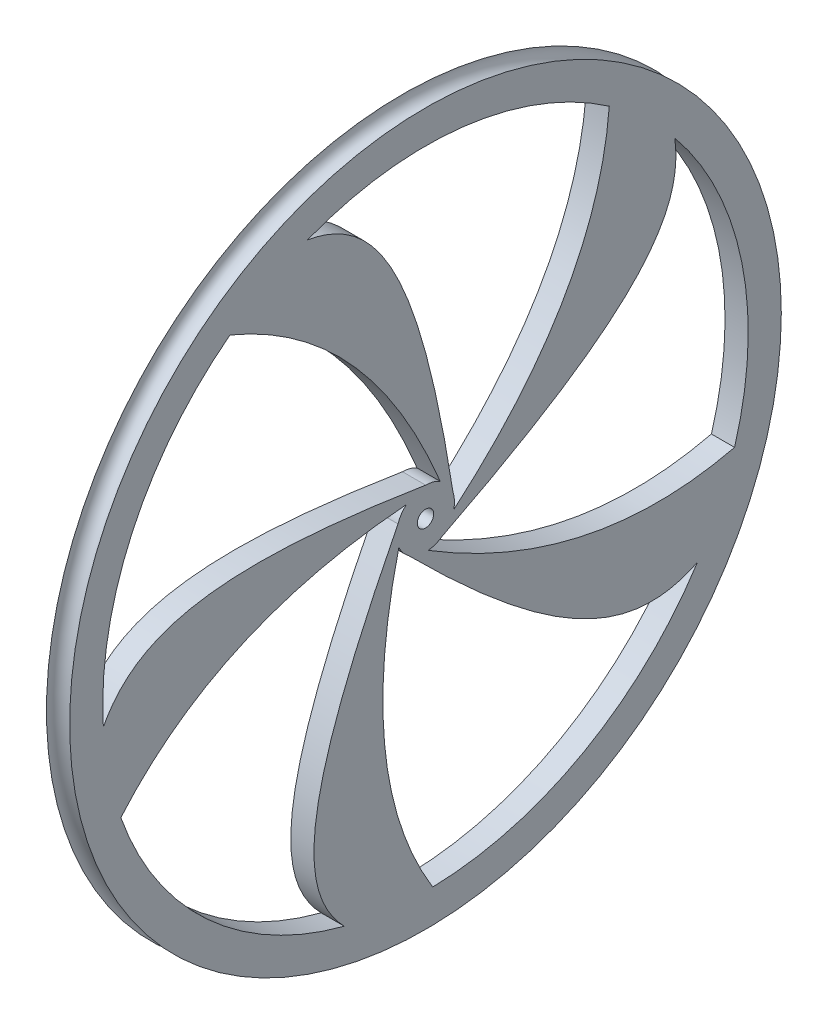
from build123d import *

# Parameters (mm, degrees)
SKETCH3_R           = 4.445
SKETCH3_R_2         = 1.2573
BOSS_EXTRUDE1_DEPTH = 1.778
BOSS_EXTRUDE2_DEPTH = 1.778
CIRPATTERN1_COUNT   = 5


with BuildPart() as part:
    # Sketch1 → Revolve1 (revolve)
    with BuildSketch(Plane.XY):
        with BuildLine():
            Line((-1.778, 49.53), (1.778, 49.53))
            Line((1.778, 49.53), (1.778, 54.61))
            ThreePointArc((1.778, 54.61), (0, 52.832), (-1.778, 54.61))
            Line((-1.778, 54.61), (-1.778, 49.53))
        make_face()
    revolve(axis=Axis((0, 0, 0), (-1, 0, 0)))



with BuildPart() as body_2:
    # Sketch3 → Boss-Extrude1 (new body, symmetric)
    with BuildSketch(Plane(origin=(0, 0, 0), x_dir=(0, 0, -1), z_dir=(1, 0, 0))):
        Circle(SKETCH3_R)
        Circle(SKETCH3_R_2, mode=Mode.SUBTRACT)
    extrude(amount=BOSS_EXTRUDE1_DEPTH, both=True)


with BuildPart() as part_1:
    add(part.part)

    add(body_2.part)  # Boss-Extrude2 merges body 2
    # Sketch4 → Boss-Extrude2 (add, symmetric)
    with BuildSketch(Plane(origin=(0, 0, 0), x_dir=(0, 0, -1), z_dir=(1, 0, 0))):
        with BuildLine():
            add(Edge.make_bspline(
                [(4.236760603, 1.34457599), (-0.842126183, 33.70804678), (-7.397626382, 44.22942933), (-18.096543838, 46.105704648)],
                knots=[0.007889083, 0.007889083, 0.007889083, 0.007889083, 0.582841342, 0.582841342, 0.582841342, 0.582841342], degree=3))
            ThreePointArc((-18.096543838, 46.105704648), (-24.282655216, 43.169127344), (-30.004622023, 39.407404853))
            add(Edge.make_bspline(
                [(2.269041799, 3.822234204), (-8.811754066, 30.630525708), (-30.004622023, 39.407404853)],
                knots=[0, 0, 0, 0.677750608, 0.677750608, 0.677750608], degree=2))
            ThreePointArc((2.269041799, 3.822234204), (3.480813667, 2.764409742), (4.236760603, 1.34457599))
        make_face()
    boss_extrude2 = extrude(amount=BOSS_EXTRUDE2_DEPTH, both=True)

    # CirPattern1: Boss-Extrude2 ×5 about axis
    cirpattern1_axis = Axis((0, 0, 0), (1, 0, 0))
    for i in range(1, CIRPATTERN1_COUNT):
        add(boss_extrude2.rotate(cirpattern1_axis, i * 360 / CIRPATTERN1_COUNT))


solid = part_1.part
